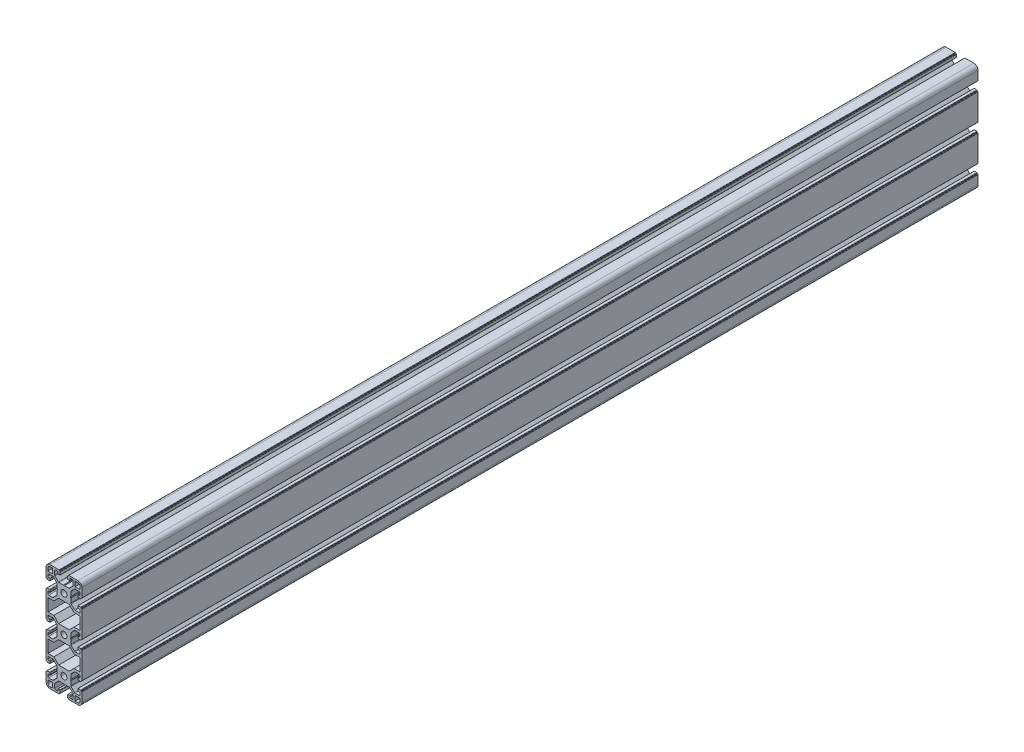
from build123d import *

# Parameters (mm, degrees)
SKETCH_1_R      = 3.4
EXTRUDE_1_DEPTH = 1000


with BuildPart() as part:
    # Эскиз1 → Бобышка-Вытянуть1 (new body)
    with BuildSketch(Plane.XY):
        with BuildLine():
            Line((-20, 10.25), (-20, 15.5))
            ThreePointArc((-20, 15.5), (-18.681980515, 18.681980515), (-15.5, 20))
            Line((-15.5, 20), (-10.25, 20))
            Line((-10.25, 20), (-5.4, 20))
            ThreePointArc((-5.4, 20), (-5.187867966, 19.912132034), (-5.1, 19.7))
            Line((-5.1, 19.7), (-5.1, 19))
            Line((-5.1, 19), (-4.4, 19))
            ThreePointArc((-4.4, 19), (-4.187867966, 18.912132034), (-4.1, 18.7))
            Line((-4.1, 18.7), (-4.1, 15.8))
            ThreePointArc((-4.1, 15.8), (-4.187867966, 15.587867966), (-4.4, 15.5))
            Line((-4.4, 15.5), (-6.3, 15.5))
            ThreePointArc((-6.3, 15.5), (-6.512132034, 15.587867966), (-6.6, 15.8))
            Line((-6.6, 15.8), (-6.6, 17))
            ThreePointArc((-6.6, 17), (-6.892893219, 17.707106781), (-7.6, 18))
            Line((-7.6, 18), (-9.25, 18))
            ThreePointArc((-9.25, 18), (-9.957106781, 17.707106781), (-10.25, 17))
            Line((-10.25, 17), (-10.25, 12.464213562))
            ThreePointArc((-10.25, 12.464213562), (-10.173879533, 12.08153013), (-9.957106781, 11.757106781))
            Line((-9.957106781, 11.757106781), (-6.192893219, 7.992893219))
            ThreePointArc((-6.192893219, 7.992893219), (-5.86846987, 7.776120467), (-5.485786438, 7.7))
            Line((-5.485786438, 7.7), (-0.6, 7.7))
            Line((-0.6, 7.7), (0, 7.1))
            Line((0, 7.1), (0.6, 7.7))
            Line((0.6, 7.7), (5.485786438, 7.7))
            ThreePointArc((5.485786438, 7.7), (5.86846987, 7.776120467), (6.192893219, 7.992893219))
            Line((6.192893219, 7.992893219), (9.957106781, 11.757106781))
            ThreePointArc((9.957106781, 11.757106781), (10.173879533, 12.08153013), (10.25, 12.464213562))
            Line((10.25, 12.464213562), (10.25, 17))
            ThreePointArc((10.25, 17), (9.957106781, 17.707106781), (9.25, 18))
            Line((9.25, 18), (7.6, 18))
            ThreePointArc((7.6, 18), (6.892893219, 17.707106781), (6.6, 17))
            Line((6.6, 17), (6.6, 15.8))
            ThreePointArc((6.6, 15.8), (6.512132034, 15.587867966), (6.3, 15.5))
            Line((6.3, 15.5), (4.4, 15.5))
            ThreePointArc((4.4, 15.5), (4.187867966, 15.587867966), (4.1, 15.8))
            Line((4.1, 15.8), (4.1, 18.7))
            ThreePointArc((4.1, 18.7), (4.187867966, 18.912132034), (4.4, 19))
            Line((4.4, 19), (5.1, 19))
            Line((5.1, 19), (5.1, 19.7))
            ThreePointArc((5.1, 19.7), (5.187867966, 19.912132034), (5.4, 20))
            Line((5.4, 20), (10.25, 20))
            Line((10.25, 20), (15.5, 20))
            ThreePointArc((15.5, 20), (18.681980515, 18.681980515), (20, 15.5))
            Line((20, 15.5), (20, 10.25))
            Line((20, 10.25), (20, 5.4))
            ThreePointArc((20, 5.4), (19.912132034, 5.187867966), (19.7, 5.1))
            Line((19.7, 5.1), (19, 5.1))
            Line((19, 5.1), (19, 4.4))
            ThreePointArc((19, 4.4), (18.912132034, 4.187867966), (18.7, 4.1))
            Line((18.7, 4.1), (15.8, 4.1))
            ThreePointArc((15.8, 4.1), (15.587867966, 4.187867966), (15.5, 4.4))
            Line((15.5, 4.4), (15.5, 6.3))
            ThreePointArc((15.5, 6.3), (15.587867966, 6.512132034), (15.8, 6.6))
            Line((15.8, 6.6), (17, 6.6))
            ThreePointArc((17, 6.6), (17.707106781, 6.892893219), (18, 7.6))
            Line((18, 7.6), (18, 9.25))
            ThreePointArc((18, 9.25), (17.707106781, 9.957106781), (17, 10.25))
            Line((17, 10.25), (12.464213562, 10.25))
            ThreePointArc((12.464213562, 10.25), (12.08153013, 10.173879533), (11.757106781, 9.957106781))
            Line((11.757106781, 9.957106781), (7.992893219, 6.192893219))
            ThreePointArc((7.992893219, 6.192893219), (7.776120467, 5.86846987), (7.7, 5.485786438))
            Line((7.7, 5.485786438), (7.7, 0.6))
            Line((7.7, 0.6), (7.1, 0))
            Line((7.1, 0), (7.7, -0.6))
            Line((7.7, -0.6), (7.7, -5.485786438))
            ThreePointArc((7.7, -5.485786438), (7.776120467, -5.86846987), (7.992893219, -6.192893219))
            Line((7.992893219, -6.192893219), (11.757106781, -9.957106781))
            ThreePointArc((11.757106781, -9.957106781), (12.08153013, -10.173879533), (12.464213562, -10.25))
            Line((12.464213562, -10.25), (17, -10.25))
            ThreePointArc((17, -10.25), (17.707106781, -9.957106781), (18, -9.25))
            Line((18, -9.25), (18, -7.6))
            ThreePointArc((18, -7.6), (17.707106781, -6.892893219), (17, -6.6))
            Line((17, -6.6), (15.8, -6.6))
            ThreePointArc((15.8, -6.6), (15.587867966, -6.512132034), (15.5, -6.3))
            Line((15.5, -6.3), (15.5, -4.4))
            ThreePointArc((15.5, -4.4), (15.587867966, -4.187867966), (15.8, -4.1))
            Line((15.8, -4.1), (18.7, -4.1))
            ThreePointArc((18.7, -4.1), (18.912132034, -4.187867966), (19, -4.4))
            Line((19, -4.4), (19, -5.1))
            Line((19, -5.1), (19.7, -5.1))
            ThreePointArc((19.7, -5.1), (19.912132034, -5.187867966), (20, -5.4))
            Line((20, -5.4), (20, -10.25))
            Line((20, -10.25), (20, -29.75))
            Line((20, -29.75), (20, -34.6))
            ThreePointArc((20, -34.6), (19.912132034, -34.812132034), (19.7, -34.9))
            Line((19.7, -34.9), (19, -34.9))
            Line((19, -34.9), (19, -35.6))
            ThreePointArc((19, -35.6), (18.912132034, -35.812132034), (18.7, -35.9))
            Line((18.7, -35.9), (15.8, -35.9))
            ThreePointArc((15.8, -35.9), (15.587867966, -35.812132034), (15.5, -35.6))
            Line((15.5, -35.6), (15.5, -33.7))
            ThreePointArc((15.5, -33.7), (15.587867966, -33.487867966), (15.8, -33.4))
            Line((15.8, -33.4), (17, -33.4))
            ThreePointArc((17, -33.4), (17.707106781, -33.107106781), (18, -32.4))
            Line((18, -32.4), (18, -30.75))
            ThreePointArc((18, -30.75), (17.707106781, -30.042893219), (17, -29.75))
            Line((17, -29.75), (12.464213562, -29.75))
            ThreePointArc((12.464213562, -29.75), (12.08153013, -29.826120467), (11.757106781, -30.042893219))
            Line((11.757106781, -30.042893219), (7.992893219, -33.807106781))
            ThreePointArc((7.992893219, -33.807106781), (7.776120467, -34.13153013), (7.7, -34.514213562))
            Line((7.7, -34.514213562), (7.7, -39.4))
            Line((7.7, -39.4), (7.1, -40))
            Line((7.1, -40), (7.7, -40.6))
            Line((7.7, -40.6), (7.7, -45.485786438))
            ThreePointArc((7.7, -45.485786438), (7.776120467, -45.86846987), (7.992893219, -46.192893219))
            Line((7.992893219, -46.192893219), (11.757106781, -49.957106781))
            ThreePointArc((11.757106781, -49.957106781), (12.08153013, -50.173879533), (12.464213562, -50.25))
            Line((12.464213562, -50.25), (17, -50.25))
            ThreePointArc((17, -50.25), (17.707106781, -49.957106781), (18, -49.25))
            Line((18, -49.25), (18, -47.6))
            ThreePointArc((18, -47.6), (17.707106781, -46.892893219), (17, -46.6))
            Line((17, -46.6), (15.8, -46.6))
            ThreePointArc((15.8, -46.6), (15.587867966, -46.512132034), (15.5, -46.3))
            Line((15.5, -46.3), (15.5, -44.4))
            ThreePointArc((15.5, -44.4), (15.587867966, -44.187867966), (15.8, -44.1))
            Line((15.8, -44.1), (18.7, -44.1))
            ThreePointArc((18.7, -44.1), (18.912132034, -44.187867966), (19, -44.4))
            Line((19, -44.4), (19, -45.1))
            Line((19, -45.1), (19.7, -45.1))
            ThreePointArc((19.7, -45.1), (19.912132034, -45.187867966), (20, -45.4))
            Line((20, -45.4), (20, -50.25))
            Line((20, -50.25), (20, -69.75))
            Line((20, -69.75), (20, -74.6))
            ThreePointArc((20, -74.6), (19.912132034, -74.812132034), (19.7, -74.9))
            Line((19.7, -74.9), (19, -74.9))
            Line((19, -74.9), (19, -75.6))
            ThreePointArc((19, -75.6), (18.912132034, -75.812132034), (18.7, -75.9))
            Line((18.7, -75.9), (15.8, -75.9))
            ThreePointArc((15.8, -75.9), (15.587867966, -75.812132034), (15.5, -75.6))
            Line((15.5, -75.6), (15.5, -73.7))
            ThreePointArc((15.5, -73.7), (15.587867966, -73.487867966), (15.8, -73.4))
            Line((15.8, -73.4), (17, -73.4))
            ThreePointArc((17, -73.4), (17.707106781, -73.107106781), (18, -72.4))
            Line((18, -72.4), (18, -70.75))
            ThreePointArc((18, -70.75), (17.707106781, -70.042893219), (17, -69.75))
            Line((17, -69.75), (12.464213562, -69.75))
            ThreePointArc((12.464213562, -69.75), (12.08153013, -69.826120467), (11.757106781, -70.042893219))
            Line((11.757106781, -70.042893219), (7.992893219, -73.807106781))
            ThreePointArc((7.992893219, -73.807106781), (7.776120467, -74.13153013), (7.7, -74.514213562))
            Line((7.7, -74.514213562), (7.7, -79.4))
            Line((7.7, -79.4), (7.1, -80))
            Line((7.1, -80), (7.7, -80.6))
            Line((7.7, -80.6), (7.7, -85.485786438))
            ThreePointArc((7.7, -85.485786438), (7.776120467, -85.86846987), (7.992893219, -86.192893219))
            Line((7.992893219, -86.192893219), (11.757106781, -89.957106781))
            ThreePointArc((11.757106781, -89.957106781), (12.08153013, -90.173879533), (12.464213562, -90.25))
            Line((12.464213562, -90.25), (17, -90.25))
            ThreePointArc((17, -90.25), (17.707106781, -89.957106781), (18, -89.25))
            Line((18, -89.25), (18, -87.6))
            ThreePointArc((18, -87.6), (17.707106781, -86.892893219), (17, -86.6))
            Line((17, -86.6), (15.8, -86.6))
            ThreePointArc((15.8, -86.6), (15.587867966, -86.512132034), (15.5, -86.3))
            Line((15.5, -86.3), (15.5, -84.4))
            ThreePointArc((15.5, -84.4), (15.587867966, -84.187867966), (15.8, -84.1))
            Line((15.8, -84.1), (18.7, -84.1))
            ThreePointArc((18.7, -84.1), (18.912132034, -84.187867966), (19, -84.4))
            Line((19, -84.4), (19, -85.1))
            Line((19, -85.1), (19.7, -85.1))
            ThreePointArc((19.7, -85.1), (19.912132034, -85.187867966), (20, -85.4))
            Line((20, -85.4), (20, -90.25))
            Line((20, -90.25), (20, -95.5))
            ThreePointArc((20, -95.5), (18.681980515, -98.681980515), (15.5, -100))
            Line((15.5, -100), (10.25, -100))
            Line((10.25, -100), (5.4, -100))
            ThreePointArc((5.4, -100), (5.187867966, -99.912132034), (5.1, -99.7))
            Line((5.1, -99.7), (5.1, -99))
            Line((5.1, -99), (4.4, -99))
            ThreePointArc((4.4, -99), (4.187867966, -98.912132034), (4.1, -98.7))
            Line((4.1, -98.7), (4.1, -95.8))
            ThreePointArc((4.1, -95.8), (4.187867966, -95.587867966), (4.4, -95.5))
            Line((4.4, -95.5), (6.3, -95.5))
            ThreePointArc((6.3, -95.5), (6.512132034, -95.587867966), (6.6, -95.8))
            Line((6.6, -95.8), (6.6, -97))
            ThreePointArc((6.6, -97), (6.892893219, -97.707106781), (7.6, -98))
            Line((7.6, -98), (9.25, -98))
            ThreePointArc((9.25, -98), (9.957106781, -97.707106781), (10.25, -97))
            Line((10.25, -97), (10.25, -92.464213562))
            ThreePointArc((10.25, -92.464213562), (10.173879533, -92.08153013), (9.957106781, -91.757106781))
            Line((9.957106781, -91.757106781), (6.192893219, -87.992893219))
            ThreePointArc((6.192893219, -87.992893219), (5.86846987, -87.776120467), (5.485786438, -87.7))
            Line((5.485786438, -87.7), (0.6, -87.7))
            Line((0.6, -87.7), (0, -87.1))
            Line((0, -87.1), (-0.6, -87.7))
            Line((-0.6, -87.7), (-5.485786438, -87.7))
            ThreePointArc((-5.485786438, -87.7), (-5.86846987, -87.776120467), (-6.192893219, -87.992893219))
            Line((-6.192893219, -87.992893219), (-9.957106781, -91.757106781))
            ThreePointArc((-9.957106781, -91.757106781), (-10.173879533, -92.08153013), (-10.25, -92.464213562))
            Line((-10.25, -92.464213562), (-10.25, -97))
            ThreePointArc((-10.25, -97), (-9.957106781, -97.707106781), (-9.25, -98))
            Line((-9.25, -98), (-7.6, -98))
            ThreePointArc((-7.6, -98), (-6.892893219, -97.707106781), (-6.6, -97))
            Line((-6.6, -97), (-6.6, -95.8))
            ThreePointArc((-6.6, -95.8), (-6.512132034, -95.587867966), (-6.3, -95.5))
            Line((-6.3, -95.5), (-4.4, -95.5))
            ThreePointArc((-4.4, -95.5), (-4.187867966, -95.587867966), (-4.1, -95.8))
            Line((-4.1, -95.8), (-4.1, -98.7))
            ThreePointArc((-4.1, -98.7), (-4.187867966, -98.912132034), (-4.4, -99))
            Line((-4.4, -99), (-5.1, -99))
            Line((-5.1, -99), (-5.1, -99.7))
            ThreePointArc((-5.1, -99.7), (-5.187867966, -99.912132034), (-5.4, -100))
            Line((-5.4, -100), (-10.25, -100))
            Line((-10.25, -100), (-15.5, -100))
            ThreePointArc((-15.5, -100), (-18.681980515, -98.681980515), (-20, -95.5))
            Line((-20, -95.5), (-20, -90.25))
            Line((-20, -90.25), (-20, -85.4))
            ThreePointArc((-20, -85.4), (-19.912132034, -85.187867966), (-19.7, -85.1))
            Line((-19.7, -85.1), (-19, -85.1))
            Line((-19, -85.1), (-19, -84.4))
            ThreePointArc((-19, -84.4), (-18.912132034, -84.187867966), (-18.7, -84.1))
            Line((-18.7, -84.1), (-15.8, -84.1))
            ThreePointArc((-15.8, -84.1), (-15.587867966, -84.187867966), (-15.5, -84.4))
            Line((-15.5, -84.4), (-15.5, -86.3))
            ThreePointArc((-15.5, -86.3), (-15.587867966, -86.512132034), (-15.8, -86.6))
            Line((-15.8, -86.6), (-17, -86.6))
            ThreePointArc((-17, -86.6), (-17.707106781, -86.892893219), (-18, -87.6))
            Line((-18, -87.6), (-18, -89.25))
            ThreePointArc((-18, -89.25), (-17.707106781, -89.957106781), (-17, -90.25))
            Line((-17, -90.25), (-12.464213562, -90.25))
            ThreePointArc((-12.464213562, -90.25), (-12.08153013, -90.173879533), (-11.757106781, -89.957106781))
            Line((-11.757106781, -89.957106781), (-7.992893219, -86.192893219))
            ThreePointArc((-7.992893219, -86.192893219), (-7.776120467, -85.86846987), (-7.7, -85.485786438))
            Line((-7.7, -85.485786438), (-7.7, -80.6))
            Line((-7.7, -80.6), (-7.1, -80))
            Line((-7.1, -80), (-7.7, -79.4))
            Line((-7.7, -79.4), (-7.7, -74.514213562))
            ThreePointArc((-7.7, -74.514213562), (-7.776120467, -74.13153013), (-7.992893219, -73.807106781))
            Line((-7.992893219, -73.807106781), (-11.757106781, -70.042893219))
            ThreePointArc((-11.757106781, -70.042893219), (-12.08153013, -69.826120467), (-12.464213562, -69.75))
            Line((-12.464213562, -69.75), (-17, -69.75))
            ThreePointArc((-17, -69.75), (-17.707106781, -70.042893219), (-18, -70.75))
            Line((-18, -70.75), (-18, -72.4))
            ThreePointArc((-18, -72.4), (-17.707106781, -73.107106781), (-17, -73.4))
            Line((-17, -73.4), (-15.8, -73.4))
            ThreePointArc((-15.8, -73.4), (-15.587867966, -73.487867966), (-15.5, -73.7))
            Line((-15.5, -73.7), (-15.5, -75.6))
            ThreePointArc((-15.5, -75.6), (-15.587867966, -75.812132034), (-15.8, -75.9))
            Line((-15.8, -75.9), (-18.7, -75.9))
            ThreePointArc((-18.7, -75.9), (-18.912132034, -75.812132034), (-19, -75.6))
            Line((-19, -75.6), (-19, -74.9))
            Line((-19, -74.9), (-19.7, -74.9))
            ThreePointArc((-19.7, -74.9), (-19.912132034, -74.812132034), (-20, -74.6))
            Line((-20, -74.6), (-20, -69.75))
            Line((-20, -69.75), (-20, -50.25))
            Line((-20, -50.25), (-20, -45.4))
            ThreePointArc((-20, -45.4), (-19.912132034, -45.187867966), (-19.7, -45.1))
            Line((-19.7, -45.1), (-19, -45.1))
            Line((-19, -45.1), (-19, -44.4))
            ThreePointArc((-19, -44.4), (-18.912132034, -44.187867966), (-18.7, -44.1))
            Line((-18.7, -44.1), (-15.8, -44.1))
            ThreePointArc((-15.8, -44.1), (-15.587867966, -44.187867966), (-15.5, -44.4))
            Line((-15.5, -44.4), (-15.5, -46.3))
            ThreePointArc((-15.5, -46.3), (-15.587867966, -46.512132034), (-15.8, -46.6))
            Line((-15.8, -46.6), (-17, -46.6))
            ThreePointArc((-17, -46.6), (-17.707106781, -46.892893219), (-18, -47.6))
            Line((-18, -47.6), (-18, -49.25))
            ThreePointArc((-18, -49.25), (-17.707106781, -49.957106781), (-17, -50.25))
            Line((-17, -50.25), (-12.464213562, -50.25))
            ThreePointArc((-12.464213562, -50.25), (-12.08153013, -50.173879533), (-11.757106781, -49.957106781))
            Line((-11.757106781, -49.957106781), (-7.992893219, -46.192893219))
            ThreePointArc((-7.992893219, -46.192893219), (-7.776120467, -45.86846987), (-7.7, -45.485786438))
            Line((-7.7, -45.485786438), (-7.7, -40.6))
            Line((-7.7, -40.6), (-7.1, -40))
            Line((-7.1, -40), (-7.7, -39.4))
            Line((-7.7, -39.4), (-7.7, -34.514213562))
            ThreePointArc((-7.7, -34.514213562), (-7.776120467, -34.13153013), (-7.992893219, -33.807106781))
            Line((-7.992893219, -33.807106781), (-11.757106781, -30.042893219))
            ThreePointArc((-11.757106781, -30.042893219), (-12.08153013, -29.826120467), (-12.464213562, -29.75))
            Line((-12.464213562, -29.75), (-17, -29.75))
            ThreePointArc((-17, -29.75), (-17.707106781, -30.042893219), (-18, -30.75))
            Line((-18, -30.75), (-18, -32.4))
            ThreePointArc((-18, -32.4), (-17.707106781, -33.107106781), (-17, -33.4))
            Line((-17, -33.4), (-15.8, -33.4))
            ThreePointArc((-15.8, -33.4), (-15.587867966, -33.487867966), (-15.5, -33.7))
            Line((-15.5, -33.7), (-15.5, -35.6))
            ThreePointArc((-15.5, -35.6), (-15.587867966, -35.812132034), (-15.8, -35.9))
            Line((-15.8, -35.9), (-18.7, -35.9))
            ThreePointArc((-18.7, -35.9), (-18.912132034, -35.812132034), (-19, -35.6))
            Line((-19, -35.6), (-19, -34.9))
            Line((-19, -34.9), (-19.7, -34.9))
            ThreePointArc((-19.7, -34.9), (-19.912132034, -34.812132034), (-20, -34.6))
            Line((-20, -34.6), (-20, -29.75))
            Line((-20, -29.75), (-20, -10.25))
            Line((-20, -10.25), (-20, -5.4))
            ThreePointArc((-20, -5.4), (-19.912132034, -5.187867966), (-19.7, -5.1))
            Line((-19.7, -5.1), (-19, -5.1))
            Line((-19, -5.1), (-19, -4.4))
            ThreePointArc((-19, -4.4), (-18.912132034, -4.187867966), (-18.7, -4.1))
            Line((-18.7, -4.1), (-15.8, -4.1))
            ThreePointArc((-15.8, -4.1), (-15.587867966, -4.187867966), (-15.5, -4.4))
            Line((-15.5, -4.4), (-15.5, -6.3))
            ThreePointArc((-15.5, -6.3), (-15.587867966, -6.512132034), (-15.8, -6.6))
            Line((-15.8, -6.6), (-17, -6.6))
            ThreePointArc((-17, -6.6), (-17.707106781, -6.892893219), (-18, -7.6))
            Line((-18, -7.6), (-18, -9.25))
            ThreePointArc((-18, -9.25), (-17.707106781, -9.957106781), (-17, -10.25))
            Line((-17, -10.25), (-12.464213562, -10.25))
            ThreePointArc((-12.464213562, -10.25), (-12.08153013, -10.173879533), (-11.757106781, -9.957106781))
            Line((-11.757106781, -9.957106781), (-7.992893219, -6.192893219))
            ThreePointArc((-7.992893219, -6.192893219), (-7.776120467, -5.86846987), (-7.7, -5.485786438))
            Line((-7.7, -5.485786438), (-7.7, -0.6))
            Line((-7.7, -0.6), (-7.1, 0))
            Line((-7.1, 0), (-7.7, 0.6))
            Line((-7.7, 0.6), (-7.7, 5.485786438))
            ThreePointArc((-7.7, 5.485786438), (-7.776120467, 5.86846987), (-7.992893219, 6.192893219))
            Line((-7.992893219, 6.192893219), (-11.757106781, 9.957106781))
            ThreePointArc((-11.757106781, 9.957106781), (-12.08153013, 10.173879533), (-12.464213562, 10.25))
            Line((-12.464213562, 10.25), (-17, 10.25))
            ThreePointArc((-17, 10.25), (-17.707106781, 9.957106781), (-18, 9.25))
            Line((-18, 9.25), (-18, 7.6))
            ThreePointArc((-18, 7.6), (-17.707106781, 6.892893219), (-17, 6.6))
            Line((-17, 6.6), (-15.8, 6.6))
            ThreePointArc((-15.8, 6.6), (-15.587867966, 6.512132034), (-15.5, 6.3))
            Line((-15.5, 6.3), (-15.5, 4.4))
            ThreePointArc((-15.5, 4.4), (-15.587867966, 4.187867966), (-15.8, 4.1))
            Line((-15.8, 4.1), (-18.7, 4.1))
            ThreePointArc((-18.7, 4.1), (-18.912132034, 4.187867966), (-19, 4.4))
            Line((-19, 4.4), (-19, 5.1))
            Line((-19, 5.1), (-19.7, 5.1))
            ThreePointArc((-19.7, 5.1), (-19.912132034, 5.187867966), (-20, 5.4))
            Line((-20, 5.4), (-20, 10.25))
        make_face()
        Circle(SKETCH_1_R, mode=Mode.SUBTRACT)
        with Locations((0, -40)):
            Circle(SKETCH_1_R, mode=Mode.SUBTRACT)
        with Locations((0, -80)):
            Circle(SKETCH_1_R, mode=Mode.SUBTRACT)
        with BuildLine():
            Line((12.5, 12.5), (12.5, 18))
            Line((12.5, 18), (15.5, 18))
            ThreePointArc((15.5, 18), (17.267766953, 17.267766953), (18, 15.5))
            Line((18, 15.5), (18, 12.5))
            Line((18, 12.5), (12.5, 12.5))
        make_face(mode=Mode.SUBTRACT)
        with BuildLine():
            Line((-12.5, 12.5), (-18, 12.5))
            Line((-18, 12.5), (-18, 15.5))
            ThreePointArc((-18, 15.5), (-17.267766953, 17.267766953), (-15.5, 18))
            Line((-15.5, 18), (-12.5, 18))
            Line((-12.5, 18), (-12.5, 12.5))
        make_face(mode=Mode.SUBTRACT)
        Polygon((-17.8, -27), (-17.8, -13), (-11.264466094, -13), (-5.964466094, -7.7), (5.964466094, -7.7), (11.264466094, -13), (17.8, -13), (17.8, -27), (11.264466094, -27), (5.964466094, -32.3), (-5.964466094, -32.3), (-11.264466094, -27), align=None, mode=Mode.SUBTRACT)
        Polygon((17.8, -53), (11.264466094, -53), (5.964466094, -47.7), (-5.964466094, -47.7), (-11.264466094, -53), (-17.8, -53), (-17.8, -67), (-11.264466094, -67), (-5.964466094, -72.3), (5.964466094, -72.3), (11.264466094, -67), (17.8, -67), align=None, mode=Mode.SUBTRACT)
        with BuildLine():
            Line((12.5, -92.5), (18, -92.5))
            Line((18, -92.5), (18, -95.5))
            ThreePointArc((18, -95.5), (17.267766953, -97.267766953), (15.5, -98))
            Line((15.5, -98), (12.5, -98))
            Line((12.5, -98), (12.5, -92.5))
        make_face(mode=Mode.SUBTRACT)
        with BuildLine():
            Line((-12.5, -92.5), (-18, -92.5))
            Line((-18, -92.5), (-18, -95.5))
            ThreePointArc((-18, -95.5), (-17.267766953, -97.267766953), (-15.5, -98))
            Line((-15.5, -98), (-12.5, -98))
            Line((-12.5, -98), (-12.5, -92.5))
        make_face(mode=Mode.SUBTRACT)
    extrude(amount=EXTRUDE_1_DEPTH)


solid = part.part
